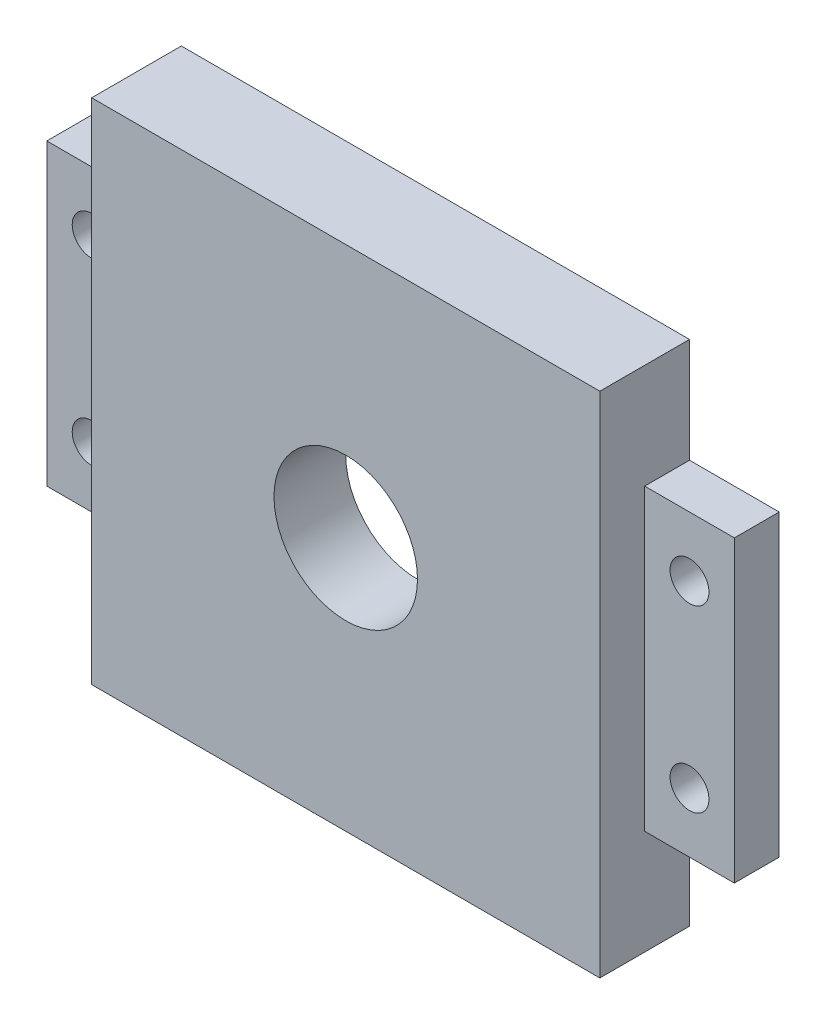
from build123d import *

# Parameters (mm, degrees)
SZKIC1_R                    = 12
DODANIE_WYCI_GNI_CIE1_DEPTH = 15
SZKIC6_R                    = 3.25
WYTNIJ_WYCI_GNI_CIE5_DEPTH  = 74.058195981
SZKIC8_W                    = 15
SZKIC8_H                    = 50
WYTNIJ_WYCI_GNI_CIE6_DEPTH  = 7.5
SZKIC9_R                    = 2.5
WYTNIJ_WYCI_GNI_CIE7_DEPTH  = 10
SZYK_KO_OWY1_COUNT          = 4
SFAZOWANIE1_SIZE            = 0.5
SZKIC10_R                   = 35
WYTNIJ_WYCI_GNI_CIE8_DEPTH  = 3


with BuildPart() as part:
    # Szkic1 → Dodanie-wyciągnięcie1 (new body)
    with BuildSketch(Plane.XY):
        Polygon((42.5, 25), (42.5, 42.5), (-42.5, 42.5), (-42.5, 25), (-57.5, 25), (-57.5, -25), (-42.5, -25), (-42.5, -42.5), (42.5, -42.5), (42.5, -25), (57.5, -25), (57.5, 25), align=None)
        Circle(SZKIC1_R, mode=Mode.SUBTRACT)
    extrude(amount=DODANIE_WYCI_GNI_CIE1_DEPTH)

    # Szkic6 → Wytnij-wyciągnięcie5 (cut, through all)
    with BuildSketch(Plane(origin=(0, 0, 0), x_dir=(-1, 0, 0), z_dir=(0, 0, -1))):
        with Locations((-50, -15)):
            Circle(SZKIC6_R)
        with Locations((-50, 15)):
            Circle(SZKIC6_R)
        with Locations((50, 15)):
            Circle(SZKIC6_R)
        with Locations((50, -15)):
            Circle(SZKIC6_R)
    extrude(amount=-WYTNIJ_WYCI_GNI_CIE5_DEPTH, mode=Mode.SUBTRACT)

    # Szkic8 → Wytnij-wyciągnięcie6 (cut)
    with BuildSketch(Plane.XY.offset(15)):
        with Locations((-50, 0)):
            Rectangle(SZKIC8_W, SZKIC8_H)
        with Locations((50, 0)):
            Rectangle(SZKIC8_W, SZKIC8_H)
    extrude(amount=-WYTNIJ_WYCI_GNI_CIE6_DEPTH, mode=Mode.SUBTRACT)

    # Szkic9 → Wytnij-wyciągnięcie7 (cut)
    with BuildSketch(Plane(origin=(0, 0, 0), x_dir=(-1, 0, 0), z_dir=(0, 0, -1))):
        with Locations((-31.819805153, 31.819805153)):
            Circle(SZKIC9_R)
    wytnij_wyci_gni_cie7 = extrude(amount=-WYTNIJ_WYCI_GNI_CIE7_DEPTH, mode=Mode.SUBTRACT)

    # Szyk kołowy1: Wytnij-wyciągnięcie7 ×4 about axis
    szyk_ko_owy1_axis = Axis((0, 0, 15), (0, 0, -1))
    for i in range(1, SZYK_KO_OWY1_COUNT):
        add(wytnij_wyci_gni_cie7.rotate(szyk_ko_owy1_axis, i * 360 / SZYK_KO_OWY1_COUNT), mode=Mode.SUBTRACT)

    # Sfazowanie1
    sfazowanie1_edges = [part.edges().sort_by_distance(p)[0] for p in [
        (34.319805153, 31.819805153, 0),
        (31.819805153, -34.319805153, 0),
        (-34.319805153, -31.819805153, 0),
        (-31.819805153, 34.319805153, 0),
    ]]
    chamfer(sfazowanie1_edges, length=SFAZOWANIE1_SIZE)

    # Szkic10 → Wytnij-wyciągnięcie8 (cut)
    with BuildSketch(Plane(origin=(0, 0, 0), x_dir=(-1, 0, 0), z_dir=(0, 0, -1))):
        Circle(SZKIC10_R)
    extrude(amount=-WYTNIJ_WYCI_GNI_CIE8_DEPTH, mode=Mode.SUBTRACT)


solid = part.part
